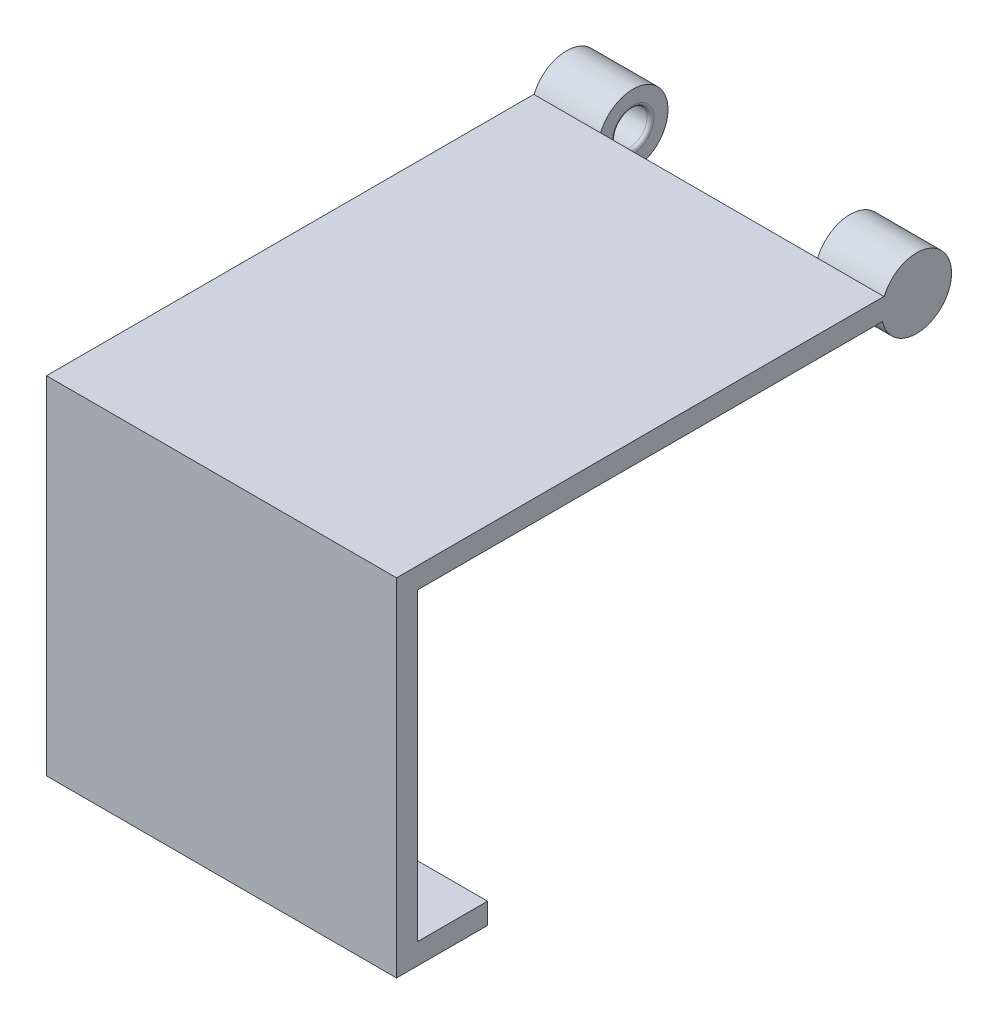
from build123d import *

# Parameters (mm, degrees)
BOSS_EXTRUDE1_DEPTH  = 50
SKETCH2_R            = 5
BOSS_EXTRUDE2_DEPTH  = 9.5
SKETCH3_R            = 2.5
CUT_EXTRUDE1_DEPTH   = 4
FILLET1_R            = 0.5
FILLET1_OF_MIRROR2_R = 0.5


with BuildPart() as part:
    # Sketch1 → Boss-Extrude1 (new body)
    with BuildSketch(Plane(origin=(0, 0, 0), x_dir=(0, 0, -1), z_dir=(1, 0, 0))):
        Polygon((0, 0), (0, 43.5), (66.6, 43.5), (66.6, 46.5), (-3, 46.5), (-3, -3), (10, -3), (10, 0), align=None)
    extrude(amount=BOSS_EXTRUDE1_DEPTH)

    # Sketch2 → Boss-Extrude2 (add)
    with BuildSketch(Plane(origin=(50, 0, 0), x_dir=(0, 0, -1), z_dir=(1, 0, 0))):
        with Locations((71.272526987, 44.565123004)):
            Circle(SKETCH2_R)
    boss_extrude2 = extrude(amount=-BOSS_EXTRUDE2_DEPTH)

    # Sketch3 → Cut-Extrude1 (cut)
    with BuildSketch(Plane.ZY.offset(-40.5)):
        with Locations((-71.272526987, 44.565123004)):
            Circle(SKETCH3_R)
    cut_extrude1 = extrude(amount=-CUT_EXTRUDE1_DEPTH, mode=Mode.SUBTRACT)

    # Fillet1
    fillet1_edges = [part.edges().sort_by_distance(p)[0] for p in [
        (40.5, 44.565123004, -73.772526987),
    ]]
    fillet(fillet1_edges, radius=FILLET1_R)

    # Mirror2: Boss-Extrude2, Cut-Extrude1 across plane
    add(boss_extrude2.mirror(Plane(origin=(25, 0, 0), x_dir=(0, 0, 1), z_dir=(1, 0, 0))))
    add(cut_extrude1.mirror(Plane(origin=(25, 0, 0), x_dir=(0, 0, 1), z_dir=(1, 0, 0))), mode=Mode.SUBTRACT)

    # Fillet1 of Mirror2
    fillet1_of_mirror2_edges = [part.edges().sort_by_distance(p)[0] for p in [
        (9.5, 44.565123004, -73.772526987),
    ]]
    fillet(fillet1_of_mirror2_edges, radius=FILLET1_OF_MIRROR2_R)


solid = part.part
